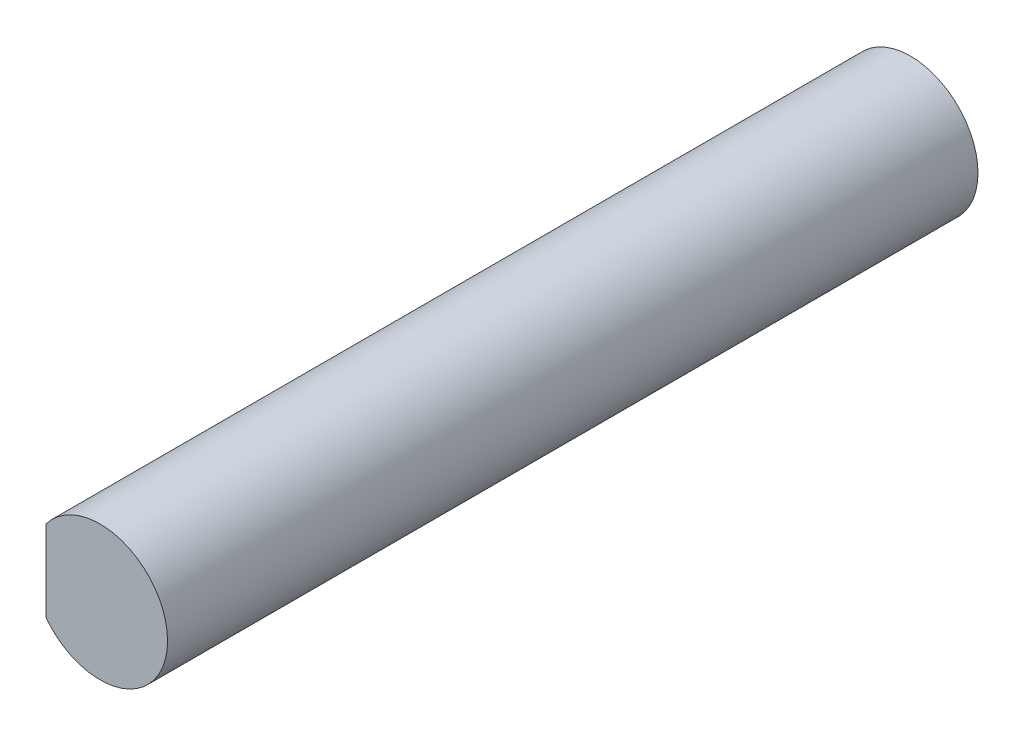
from build123d import *

# Parameters (mm, degrees)
BOSS_EXTRUDE1_START = 10
SKETCH1_R           = 5
BOSS_EXTRUDE1_DEPTH = 60
CUT_EXTRUDE1_DEPTH  = 7


with BuildPart() as part:
    # Sketch1 → Boss-Extrude1 (new body)
    with BuildSketch(Plane.XY.offset(BOSS_EXTRUDE1_START)):
        Circle(SKETCH1_R)
    extrude(amount=BOSS_EXTRUDE1_DEPTH)

    # Sketch2 → Cut-Extrude1 (cut)
    with BuildSketch(Plane.XY.offset(70)):
        with BuildLine():
            Line((-4, 3), (-4, -3))
            ThreePointArc((-4, -3), (-5, 0), (-4, 3))
        make_face()
    extrude(amount=-CUT_EXTRUDE1_DEPTH, mode=Mode.SUBTRACT)


solid = part.part
